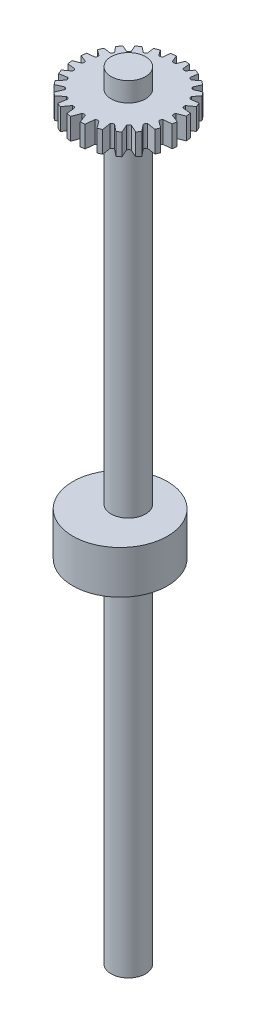
from build123d import *

# Parameters (mm, degrees)
CROQUIS1_R                   = 4
SALIENTE_EXTRUIR1_DEPTH      = 171
SALIENTE_EXTRUIR3_DEPTH      = 5
CROQUIS4_R                   = 4
SALIENTE_EXTRUIR4_DEPTH      = 4.5
CROQUIS5_R                   = 11
SALIENTE_EXTRUIR5_DEPTH      = 3
SALIENTE_EXTRUIR5_DEPTH_BACK = 7


with BuildPart() as part:
    # Croquis1 → Saliente-Extruir1 (new body)
    with BuildSketch(Plane(origin=(0, 0, 0), x_dir=(1, 0, 0), z_dir=(0, 1, 0))):
        Circle(CROQUIS1_R)
    extrude(amount=SALIENTE_EXTRUIR1_DEPTH)

    # Croquis3 → Saliente-Extruir3 (add)
    with BuildSketch(Plane(origin=(0, 171, 0), x_dir=(1, 0, 0), z_dir=(0, 1, 0))):
        with BuildLine():
            Line((1.050742858, 12.216507919), (0.472845286, 10.71499343))
            ThreePointArc((0.472845286, 10.71499343), (0, 10.543875222), (-0.472845286, 10.71499343))
            Line((-0.472845286, 10.71499343), (-1.050742858, 12.216507919))
            ThreePointArc((-1.050742858, 12.216507919), (-1.656207782, 12.14924286), (-2.257584572, 12.051988972))
            Line((-2.257584572, 12.051988972), (-2.426564451, 10.457781423))
            ThreePointArc((-2.426564451, 10.457781423), (-2.771930057, 10.239934406), (-3.179948954, 10.255912654))
            Line((-3.179948954, 10.255912654), (-4.120766374, 11.54843759))
            ThreePointArc((-4.120766374, 11.54843759), (-4.690827714, 11.328868507), (-5.249245828, 11.081179745))
            Line((-5.249245828, 11.081179745), (-5.000525386, 9.501805204))
            ThreePointArc((-5.000525386, 9.501805204), (-5.277739988, 9.201993948), (-5.675991453, 9.111824689))
            Line((-5.675991453, 9.111824689), (-6.923284582, 10.120042336))
            ThreePointArc((-6.923284582, 10.120042336), (-7.417219229, 9.763809974), (-7.892857245, 9.383492462))
            Line((-7.892857245, 9.383492462), (-7.239355878, 7.912212973))
            ThreePointArc((-7.239355878, 7.912212973), (-7.429527758, 7.55086912), (-7.790871612, 7.360697239))
            Line((-7.790871612, 7.360697239), (-9.275101788, 8.019950942))
            ThreePointArc((-9.275101788, 8.019950942), (-9.658562641, 7.553760256), (-10.018615343, 7.069262543))
            Line((-10.018615343, 7.069262543), (-8.990483327, 5.797332815))
            ThreePointArc((-8.990483327, 5.797332815), (-9.080652586, 5.39908135), (-9.380463842, 5.121866748))
            Line((-9.380463842, 5.121866748), (-11.018384727, 5.379807088))
            ThreePointArc((-11.018384727, 5.379807088), (-11.266454067, 4.838815873), (-11.487980236, 4.286424664))
            Line((-11.487980236, 4.286424664), (-10.134571292, 3.301290316))
            ThreePointArc((-10.134571292, 3.301290316), (-10.118593045, 2.893271419), (-10.336440061, 2.547905812))
            Line((-10.336440061, 2.547905812), (-12.0307187, 2.368318783))
            ThreePointArc((-12.0307187, 2.368318783), (-12.129855039, 1.792691558), (-12.201465745, 1.212996274))
            Line((-12.201465745, 1.212996274), (-10.593652069, 0.594186647))
            ThreePointArc((-10.593652069, 0.594186647), (-10.472615206, 0.204206132), (-10.593652069, -0.185774383))
            Line((-10.593652069, -0.185774383), (-12.234346993, -0.817239228))
            ThreePointArc((-12.234346993, -0.817239228), (-12.183011813, -1.386127504), (-12.105238209, -1.952007737))
            Line((-12.105238209, -1.952007737), (-10.336440061, -2.139493548))
            ThreePointArc((-10.336440061, -2.139493548), (-10.118593045, -2.484859155), (-10.134571292, -2.892878051))
            Line((-10.134571292, -2.892878051), (-11.603765461, -3.962291436))
            ThreePointArc((-11.603765461, -3.962291436), (-11.411733847, -4.485471759), (-11.196127365, -4.999385795))
            Line((-11.196127365, -4.999385795), (-9.380463842, -4.713454484))
            ThreePointArc((-9.380463842, -4.713454484), (-9.080652586, -4.990669086), (-8.990483327, -5.388920551))
            Line((-8.990483327, -5.388920551), (-10.170571543, -6.848839375))
            ThreePointArc((-10.170571543, -6.848839375), (-9.857154436, -7.29271093), (-9.524379813, -7.722261033))
            Line((-9.524379813, -7.722261033), (-7.790871612, -6.952284975))
            ThreePointArc((-7.790871612, -6.952284975), (-7.429527758, -7.142456856), (-7.239355878, -7.503800709))
            Line((-7.239355878, -7.503800709), (-8.024406446, -9.271247353))
            ThreePointArc((-8.024406446, -9.271247353), (-7.61599094, -9.60956858), (-7.193327687, -9.929912542))
            Line((-7.193327687, -9.929912542), (-5.675991453, -8.703412424))
            ThreePointArc((-5.675991453, -8.703412424), (-5.277739988, -8.793581684), (-5.000525386, -9.09339294))
            Line((-5.000525386, -9.09339294), (-5.309068741, -11.052642915))
            ThreePointArc((-5.309068741, -11.052642915), (-4.836465093, -11.26746341), (-4.355191926, -11.462086615))
            Line((-4.355191926, -11.462086615), (-3.179948954, -9.84750039))
            ThreePointArc((-3.179948954, -9.84750039), (-2.771930057, -9.831522142), (-2.426564451, -10.049369159))
            Line((-2.426564451, -10.049369159), (-2.213426541, -12.060176999))
            ThreePointArc((-2.213426541, -12.060176999), (-1.70946512, -12.141863749), (-1.202540078, -12.202500713))
            Line((-1.202540078, -12.202500713), (-0.472845286, -10.306581166))
            ThreePointArc((-0.472845286, -10.306581166), (-0.08286477, -10.185544303), (0.307115745, -10.306581166))
            Line((0.307115745, -10.306581166), (1.042474215, -12.217216287))
            ThreePointArc((1.042474215, -12.217216287), (1.544818551, -12.163908169), (2.04454079, -12.08995365))
            Line((2.04454079, -12.08995365), (2.26083491, -10.049369159))
            ThreePointArc((2.26083491, -10.049369159), (2.606200516, -9.831522142), (3.014219413, -9.84750039))
            Line((3.014219413, -9.84750039), (4.224886916, -11.510753965))
            ThreePointArc((4.224886916, -11.510753965), (4.693799885, -11.327637394), (5.154801423, -11.125428018))
            Line((5.154801423, -11.125428018), (4.834795845, -9.09339294))
            ThreePointArc((4.834795845, -9.09339294), (5.112010447, -8.793581684), (5.510261912, -8.703412424))
            Line((5.510261912, -8.703412424), (7.105542644, -9.992916993))
            ThreePointArc((7.105542644, -9.992916993), (7.511283882, -9.691632511), (7.90426552, -9.37388462))
            Line((7.90426552, -9.37388462), (7.073626337, -7.503800709))
            ThreePointArc((7.073626337, -7.503800709), (7.263798217, -7.142456856), (7.625142071, -6.952284975))
            Line((7.625142071, -6.952284975), (9.480310931, -7.776299309))
            ThreePointArc((9.480310931, -7.776299309), (9.796043302, -7.374595712), (10.094766478, -6.960087359))
            Line((10.094766478, -6.960087359), (8.824753786, -5.388920551))
            ThreePointArc((8.824753786, -5.388920551), (8.914923046, -4.990669086), (9.214734302, -4.713454484))
            Line((9.214734302, -4.713454484), (11.185209251, -5.023765551))
            ThreePointArc((11.185209251, -5.023765551), (11.388040568, -4.545289685), (11.570414703, -4.058648777))
            Line((11.570414703, -4.058648777), (9.968841751, -2.892878051))
            ThreePointArc((9.968841751, -2.892878051), (9.952863504, -2.484859155), (10.17071052, -2.139493548))
            Line((10.17071052, -2.139493548), (12.108106386, -1.934137026))
            ThreePointArc((12.108106386, -1.934137026), (12.180495026, -1.408072161), (12.230038474, -0.879366378))
            Line((12.230038474, -0.879366378), (10.427922528, -0.185774383))
            ThreePointArc((10.427922528, -0.185774383), (10.306885665, 0.204206132), (10.427922528, 0.594186647))
            Line((10.427922528, 0.594186647), (12.195208041, 1.274373229))
            ThreePointArc((12.195208041, 1.274373229), (12.12666239, 1.8141625), (12.034236318, 2.350379234))
            Line((12.034236318, 2.350379234), (10.17071052, 2.547905812))
            ThreePointArc((10.17071052, 2.547905812), (9.952863504, 2.893271419), (9.968841751, 3.301290316))
            Line((9.968841751, 3.301290316), (11.452232826, 4.381037502))
            ThreePointArc((11.452232826, 4.381037502), (11.241020253, 4.897610638), (11.006520824, 5.404037901))
            Line((11.006520824, 5.404037901), (9.214734302, 5.121866748))
            ThreePointArc((9.214734302, 5.121866748), (8.914923046, 5.39908135), (8.824753786, 5.797332815))
            Line((8.824753786, 5.797332815), (9.940895623, 7.178141856))
            ThreePointArc((9.940895623, 7.178141856), (9.595346713, 7.633901214), (9.228920544, 8.073050965))
            Line((9.228920544, 8.073050965), (7.625142071, 7.360697239))
            ThreePointArc((7.625142071, 7.360697239), (7.263798217, 7.55086912), (7.073626337, 7.912212973))
            Line((7.073626337, 7.912212973), (7.77177818, 9.48401762))
            ThreePointArc((7.77177818, 9.48401762), (7.310768329, 9.843769234), (6.83313078, 10.181132061))
            Line((6.83313078, 10.181132061), (5.510261912, 9.111824689))
            ThreePointArc((5.510261912, 9.111824689), (5.112010447, 9.201993948), (4.834795845, 9.501805204))
            Line((4.834795845, 9.501805204), (5.094829592, 11.15301922))
            ThreePointArc((5.094829592, 11.15301922), (4.547139411, 11.387302116), (3.988716959, 11.594708419))
            Line((3.988716959, 11.594708419), (3.014219413, 10.255912654))
            ThreePointArc((3.014219413, 10.255912654), (2.606200516, 10.239934406), (2.26083491, 10.457781423))
            Line((2.26083491, 10.457781423), (2.088629995, 12.082414951))
            ThreePointArc((2.088629995, 12.082414951), (1.571117662, 12.16053928), (1.050742858, 12.216507919))
        make_face()
    extrude(amount=SALIENTE_EXTRUIR3_DEPTH)

    # Croquis4 → Saliente-Extruir4 (add)
    with BuildSketch(Plane(origin=(0, 176, 0), x_dir=(1, 0, 0), z_dir=(0, 1, 0))):
        Circle(CROQUIS4_R)
    extrude(amount=SALIENTE_EXTRUIR4_DEPTH)


with BuildPart() as body_2:
    # Croquis5 → Saliente-Extruir5 (new body, two sides)
    with BuildSketch(Plane(origin=(0, 85.5, 0), x_dir=(-1, 0, 0), z_dir=(0, -1, 0))) as saliente_extruir5_sk:
        with Locations((0, -1.912427421)):
            Circle(CROQUIS5_R)
    extrude(amount=SALIENTE_EXTRUIR5_DEPTH)
    extrude(saliente_extruir5_sk.sketch, amount=-SALIENTE_EXTRUIR5_DEPTH_BACK)


solid = Compound([part.part, body_2.part])
